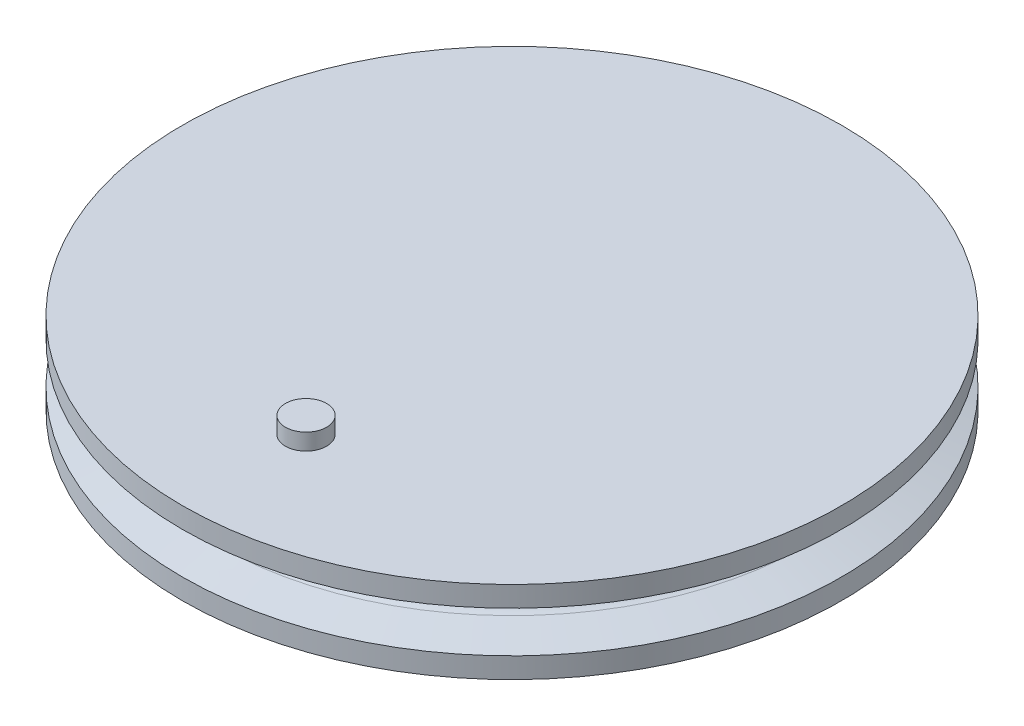
from build123d import *

# Parameters (mm, degrees)
SKETCH1_R           = 35
BOSS_EXTRUDE1_DEPTH = 10
SKETCH3_R           = 5
CUT_EXTRUDE1_DEPTH  = 5
SKETCH4_R           = 2.5
BOSS_EXTRUDE2_DEPTH = 2


with BuildPart() as part:
    # Sketch1 → Boss-Extrude1 (new body)
    with BuildSketch(Plane(origin=(0, 0, 0), x_dir=(1, 0, 0), z_dir=(0, 1, 0))):
        Circle(SKETCH1_R)
    extrude(amount=BOSS_EXTRUDE1_DEPTH)

    # Sketch2 → Revolve1 (revolve)
    with BuildSketch(Plane(origin=(0, 0, 0), x_dir=(0, 0, -1), z_dir=(1, 0, 0))):
        with BuildLine():
            Line((35, 10), (40, 10))
            Line((40, 10), (40, 7.5))
            Line((40, 7.5), (35.872288151, 6.191567774))
            ThreePointArc((35.872288151, 6.191567774), (35, 5), (35.872288151, 3.808432226))
            Line((35.872288151, 3.808432226), (40, 2.5))
            Line((40, 2.5), (40, 0))
            Line((40, 0), (35, 0))
            Line((35, 0), (34, 0))
            Line((34, 0), (34, 10))
            Line((34, 10), (35, 10))
        make_face()
    revolve(axis=Axis((0, 10, 0), (0, -1, 0)))

    # Sketch3 → Cut-Extrude1 (cut)
    with BuildSketch(Plane.XZ):
        Circle(SKETCH3_R)
    extrude(amount=-CUT_EXTRUDE1_DEPTH, mode=Mode.SUBTRACT)

    # Sketch4 → Boss-Extrude2 (add)
    with BuildSketch(Plane(origin=(0, 10, 0), x_dir=(1, 0, 0), z_dir=(0, 1, 0))):
        with Locations((0, -25)):
            Circle(SKETCH4_R)
    extrude(amount=BOSS_EXTRUDE2_DEPTH)


solid = part.part
